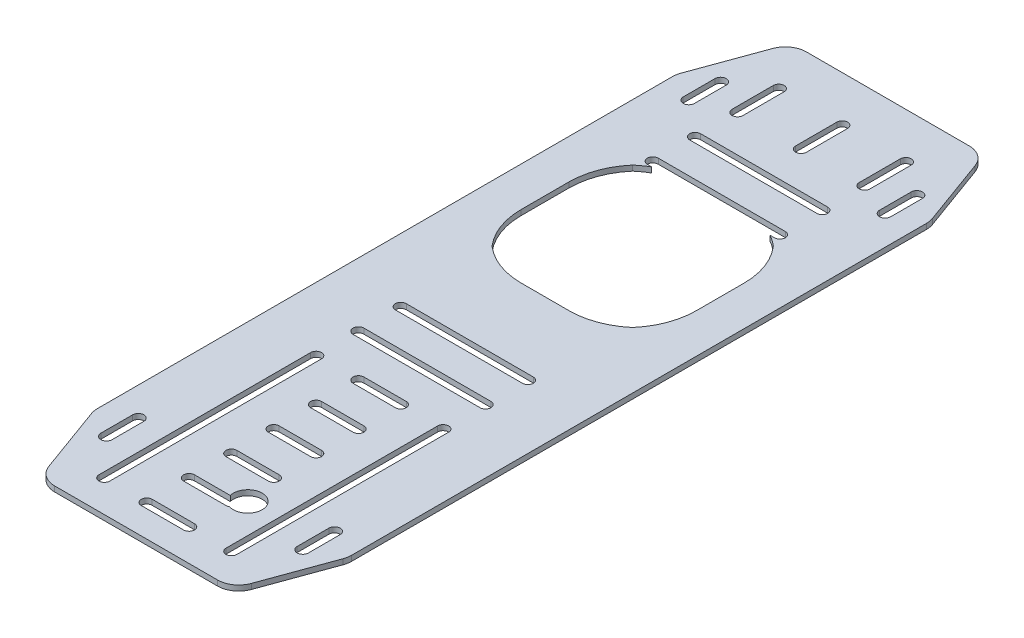
from build123d import *

# Parameters (mm, degrees)
SKETCH1_W               = 152.4
SKETCH1_H               = 660.4
BOSS_EXTRUDE1_DEPTH     = 3.18
CUT_EXTRUDE2_DEPTH      = 4.18
CUT_EXTRUDE3_DEPTH      = 4.18
CUT_EXTRUDE4_DEPTH      = 4.18
FILLET1_R               = 12.7
SKETCH6_R               = 8.636
CUT_EXTRUDE5_DEPTH      = 1
CUT_EXTRUDE5_DEPTH_BACK = 4.18
CUT_EXTRUDE6_REACH      = 5.18
SKETCH7_W               = 152.4
SKETCH7_H               = 209.55
CUT_EXTRUDE7_REACH      = 5.18
FILLET2_R               = 12.7
CUT_EXTRUDE8_REACH      = 5.18
SCALE1_SCALE            = 0.35


with BuildPart() as part:
    # Sketch1 → Boss-Extrude1 (new body)
    with BuildSketch(Plane(origin=(0, 0, 0), x_dir=(1, 0, 0), z_dir=(0, 1, 0))):
        Rectangle(SKETCH1_W, SKETCH1_H)
    extrude(amount=BOSS_EXTRUDE1_DEPTH)

    # Sketch3 → Cut-Extrude2 (cut, through all)
    with BuildSketch(Plane(origin=(0, 3.18, 0), x_dir=(1, 0, 0), z_dir=(0, 1, 0))):
        with BuildLine():
            Line((-38.1, 54.0639), (38.1, 54.0639))
            ThreePointArc((38.1, 54.0639), (41.3639, 50.8), (38.1, 47.5361))
            Line((38.1, 47.5361), (-38.1, 47.5361))
            ThreePointArc((-38.1, 47.5361), (-41.3639, 50.8), (-38.1, 54.0639))
        make_face()
        with BuildLine():
            Line((-41.3639, 25.4), (-41.3639, -101.6))
            ThreePointArc((-41.3639, -101.6), (-38.1, -104.8639), (-34.8361, -101.6))
            Line((-34.8361, -101.6), (-34.8361, 25.4))
            ThreePointArc((-34.8361, 25.4), (-38.1, 28.6639), (-41.3639, 25.4))
        make_face()
        with BuildLine():
            Line((41.3639, 25.4), (41.3639, -101.6))
            ThreePointArc((41.3639, -101.6), (38.1, -104.8639), (34.8361, -101.6))
            Line((34.8361, -101.6), (34.8361, 25.4))
            ThreePointArc((34.8361, 25.4), (38.1, 28.6639), (41.3639, 25.4))
        make_face()
        with BuildLine():
            Line((-38.1, -130.2639), (38.1, -130.2639))
            ThreePointArc((38.1, -130.2639), (41.3639, -127), (38.1, -123.7361))
            Line((38.1, -123.7361), (-38.1, -123.7361))
            ThreePointArc((-38.1, -123.7361), (-41.3639, -127), (-38.1, -130.2639))
        make_face()
        with BuildLine():
            Line((41.3639, -279.4), (41.3639, -152.4))
            ThreePointArc((41.3639, -152.4), (38.1, -149.1361), (34.8361, -152.4))
            Line((34.8361, -152.4), (34.8361, -279.4))
            ThreePointArc((34.8361, -279.4), (38.1, -282.6639), (41.3639, -279.4))
        make_face()
        with BuildLine():
            Line((-41.3639, -279.4), (-41.3639, -152.4))
            ThreePointArc((-41.3639, -152.4), (-38.1, -149.1361), (-34.8361, -152.4))
            Line((-34.8361, -152.4), (-34.8361, -279.4))
            ThreePointArc((-34.8361, -279.4), (-38.1, -282.6639), (-41.3639, -279.4))
        make_face()
        with BuildLine():
            Line((-38.1, -301.5361), (38.1, -301.5361))
            ThreePointArc((38.1, -301.5361), (41.3639, -304.8), (38.1, -308.0639))
            Line((38.1, -308.0639), (-38.1, -308.0639))
            ThreePointArc((-38.1, -308.0639), (-41.3639, -304.8), (-38.1, -301.5361))
        make_face()
        with BuildLine():
            Line((-12.7, -276.1361), (12.7, -276.1361))
            ThreePointArc((12.7, -276.1361), (15.9639, -279.4), (12.7, -282.6639))
            Line((12.7, -282.6639), (-12.7, -282.6639))
            ThreePointArc((-12.7, -282.6639), (-15.9639, -279.4), (-12.7, -276.1361))
        make_face()
        with BuildLine():
            Line((-12.7, -250.7361), (12.7, -250.7361))
            ThreePointArc((12.7, -250.7361), (15.9639, -254), (12.7, -257.2639))
            Line((12.7, -257.2639), (-12.7, -257.2639))
            ThreePointArc((-12.7, -257.2639), (-15.9639, -254), (-12.7, -250.7361))
        make_face()
        with BuildLine():
            Line((-12.7, -225.3361), (12.7, -225.3361))
            ThreePointArc((12.7, -225.3361), (15.9639, -228.6), (12.7, -231.8639))
            Line((12.7, -231.8639), (-12.7, -231.8639))
            ThreePointArc((-12.7, -231.8639), (-15.9639, -228.6), (-12.7, -225.3361))
        make_face()
        with BuildLine():
            Line((-12.7, -199.9361), (12.7, -199.9361))
            ThreePointArc((12.7, -199.9361), (15.9639, -203.2), (12.7, -206.4639))
            Line((12.7, -206.4639), (-12.7, -206.4639))
            ThreePointArc((-12.7, -206.4639), (-15.9639, -203.2), (-12.7, -199.9361))
        make_face()
        with BuildLine():
            Line((-12.7, -174.5361), (12.7, -174.5361))
            ThreePointArc((12.7, -174.5361), (15.9639, -177.8), (12.7, -181.0639))
            Line((12.7, -181.0639), (-12.7, -181.0639))
            ThreePointArc((-12.7, -181.0639), (-15.9639, -177.8), (-12.7, -174.5361))
        make_face()
        with BuildLine():
            Line((-12.7, -149.1361), (12.7, -149.1361))
            ThreePointArc((12.7, -149.1361), (15.9639, -152.4), (12.7, -155.6639))
            Line((12.7, -155.6639), (-12.7, -155.6639))
            ThreePointArc((-12.7, -155.6639), (-15.9639, -152.4), (-12.7, -149.1361))
        make_face()
        with BuildLine():
            Line((-12.7, 22.1361), (12.7, 22.1361))
            ThreePointArc((12.7, 22.1361), (15.9639, 25.4), (12.7, 28.6639))
            Line((12.7, 28.6639), (-12.7, 28.6639))
            ThreePointArc((-12.7, 28.6639), (-15.9639, 25.4), (-12.7, 22.1361))
        make_face()
        with BuildLine():
            Line((-12.7, -3.2639), (12.7, -3.2639))
            ThreePointArc((12.7, -3.2639), (15.9639, 0), (12.7, 3.2639))
            Line((12.7, 3.2639), (-12.7, 3.2639))
            ThreePointArc((-12.7, 3.2639), (-15.9639, 0), (-12.7, -3.2639))
        make_face()
        with BuildLine():
            Line((-12.7, -28.6639), (12.7, -28.6639))
            ThreePointArc((12.7, -28.6639), (15.9639, -25.4), (12.7, -22.1361))
            Line((12.7, -22.1361), (-12.7, -22.1361))
            ThreePointArc((-12.7, -22.1361), (-15.9639, -25.4), (-12.7, -28.6639))
        make_face()
        with BuildLine():
            Line((-12.7, -54.0639), (12.7, -54.0639))
            ThreePointArc((12.7, -54.0639), (15.9639, -50.8), (12.7, -47.5361))
            Line((12.7, -47.5361), (-12.7, -47.5361))
            ThreePointArc((-12.7, -47.5361), (-15.9639, -50.8), (-12.7, -54.0639))
        make_face()
        with BuildLine():
            Line((-12.7, -79.4639), (12.7, -79.4639))
            ThreePointArc((12.7, -79.4639), (15.9639, -76.2), (12.7, -72.9361))
            Line((12.7, -72.9361), (-12.7, -72.9361))
            ThreePointArc((-12.7, -72.9361), (-15.9639, -76.2), (-12.7, -79.4639))
        make_face()
        with BuildLine():
            Line((-12.7, -104.8639), (12.7, -104.8639))
            ThreePointArc((12.7, -104.8639), (15.9639, -101.6), (12.7, -98.3361))
            Line((12.7, -98.3361), (-12.7, -98.3361))
            ThreePointArc((-12.7, -98.3361), (-15.9639, -101.6), (-12.7, -104.8639))
        make_face()
        with BuildLine():
            Line((-38.1, 72.9361), (38.1, 72.9361))
            ThreePointArc((38.1, 72.9361), (41.3639, 76.2), (38.1, 79.4639))
            Line((38.1, 79.4639), (-38.1, 79.4639))
            ThreePointArc((-38.1, 79.4639), (-41.3639, 76.2), (-38.1, 72.9361))
        make_face()
        with BuildLine():
            Line((-38.1, 230.599488), (38.1, 230.599488))
            ThreePointArc((38.1, 230.599488), (41.3639, 227.335588), (38.1, 224.071688))
            Line((38.1, 224.071688), (-38.1, 224.071688))
            ThreePointArc((-38.1, 224.071688), (-41.3639, 227.335588), (-38.1, 230.599488))
        make_face()
        with BuildLine():
            Line((-38.1, 249.471688), (38.1, 249.471688))
            ThreePointArc((38.1, 249.471688), (41.3639, 252.735588), (38.1, 255.999488))
            Line((38.1, 255.999488), (-38.1, 255.999488))
            ThreePointArc((-38.1, 255.999488), (-41.3639, 252.735588), (-38.1, 249.471688))
        make_face()
        with BuildLine():
            Line((-34.8361, 302.83925906), (-34.8361, 278.135588))
            ThreePointArc((-34.8361, 278.135588), (-38.1, 274.871688), (-41.3639, 278.135588))
            Line((-41.3639, 278.135588), (-41.3639, 302.83925906))
            ThreePointArc((-41.3639, 302.83925906), (-38.1, 306.10315906), (-34.8361, 302.83925906))
        make_face()
        with BuildLine():
            Line((3.2639, 302.83925906), (3.2639, 278.135588))
            ThreePointArc((3.2639, 278.135588), (0, 274.871688), (-3.2639, 278.135588))
            Line((-3.2639, 278.135588), (-3.2639, 302.83925906))
            ThreePointArc((-3.2639, 302.83925906), (0, 306.10315906), (3.2639, 302.83925906))
        make_face()
        with BuildLine():
            Line((41.3639, 302.83925906), (41.3639, 278.135588))
            ThreePointArc((41.3639, 278.135588), (38.1, 274.871688), (34.8361, 278.135588))
            Line((34.8361, 278.135588), (34.8361, 302.83925906))
            ThreePointArc((34.8361, 302.83925906), (38.1, 306.10315906), (41.3639, 302.83925906))
        make_face()
    extrude(amount=-CUT_EXTRUDE2_DEPTH, mode=Mode.SUBTRACT)

    # Sketch4 → Cut-Extrude3 (cut, through all)
    with BuildSketch(Plane(origin=(0, 3.18, 0), x_dir=(1, 0, 0), z_dir=(0, 1, 0))):
        with BuildLine():
            Line((-14.361406616, 124.611310304), (14.361406616, 124.611310304))
            ThreePointArc((14.361406616, 124.611310304), (29.204496188, 127.284854581), (42.181875503, 134.969434801))
            ThreePointArc((42.181875503, 134.969434801), (49.866455724, 147.946814116), (52.54, 162.789903688))
            Line((52.54, 162.789903688), (52.54, 191.512716921))
            ThreePointArc((52.54, 191.512716921), (49.866455724, 206.355806493), (42.181875503, 219.333185808))
            ThreePointArc((42.181875503, 219.333185808), (29.204496188, 227.017766028), (14.361406616, 229.691310304))
            Line((14.361406616, 229.691310304), (-14.361406616, 229.691310304))
            ThreePointArc((-14.361406616, 229.691310304), (-29.204496188, 227.017766028), (-42.181875503, 219.333185808))
            ThreePointArc((-42.181875503, 219.333185808), (-49.866455724, 206.355806493), (-52.54, 191.512716921))
            Line((-52.54, 191.512716921), (-52.54, 162.789903688))
            ThreePointArc((-52.54, 162.789903688), (-49.866455724, 147.946814116), (-42.181875503, 134.969434801))
            ThreePointArc((-42.181875503, 134.969434801), (-29.204496188, 127.284854581), (-14.361406616, 124.611310304))
        make_face()
    extrude(amount=-CUT_EXTRUDE3_DEPTH, mode=Mode.SUBTRACT)

    # Sketch5 → Cut-Extrude4 (cut, through all)
    with BuildSketch(Plane.XZ):
        Polygon((76.2, 279.4), (57.710312099, 330.2), (76.2, 330.2), align=None)
        Polygon((-57.710312099, 330.2), (-76.2, 330.2), (-76.2, 279.4), align=None)
        Polygon((-76.2, -279.4), (-57.710312099, -330.2), (-76.2, -330.2), align=None)
        Polygon((57.710312099, -330.2), (76.2, -330.2), (76.2, -279.4), align=None)
    extrude(amount=-CUT_EXTRUDE4_DEPTH, mode=Mode.SUBTRACT)

    # Fillet1
    fillet1_edges = [part.edges().sort_by_distance(p)[0] for p in [
        (57.710312099, 1.59, -330.2),
        (76.2, 1.59, -279.4),
        (-76.2, 1.59, -279.4),
        (-57.710312099, 1.59, -330.2),
        (-57.710312099, 1.59, 330.2),
        (-76.2, 1.59, 279.4),
        (76.2, 1.59, 279.4),
        (57.710312099, 1.59, 330.2),
    ]]
    fillet(fillet1_edges, radius=FILLET1_R)

    # Sketch6 → Cut-Extrude5 (cut, two sides)
    with BuildSketch(Plane(origin=(0, 3.18, 0), x_dir=(1, 0, 0), z_dir=(0, 1, 0))) as cut_extrude5_sk:
        with Locations((17.106, -70.8034)):
            Circle(SKETCH6_R)
    extrude(amount=CUT_EXTRUDE5_DEPTH, mode=Mode.SUBTRACT)
    extrude(cut_extrude5_sk.sketch, amount=-CUT_EXTRUDE5_DEPTH_BACK, mode=Mode.SUBTRACT)

    # Sketch7 → Cut-Extrude6 (cut, up to next)
    with BuildSketch(Plane.XZ, mode=Mode.PRIVATE) as cut_extrude6_sk1:
        with Locations((0, 225.425)):
            Rectangle(SKETCH7_W, SKETCH7_H)
    cut_extrude6_tool1 = extrude(cut_extrude6_sk1.sketch, amount=-CUT_EXTRUDE6_REACH, mode=Mode.PRIVATE) & part.part
    add(cut_extrude6_tool1.solids().sort_by_distance((0, 0, 225.425))[0], mode=Mode.SUBTRACT)

    # Sketch8 → Cut-Extrude7 (cut, up to next)
    with BuildSketch(Plane.XZ, mode=Mode.PRIVATE) as cut_extrude7_sk1:
        Polygon((76.2, 69.85), (76.2, 120.65), (57.710312099, 120.65), align=None)
    cut_extrude7_tool1 = extrude(cut_extrude7_sk1.sketch, amount=-CUT_EXTRUDE7_REACH, mode=Mode.PRIVATE) & part.part
    add(cut_extrude7_tool1.solids().sort_by_distance((70.036771, 0, 103.716667))[0], mode=Mode.SUBTRACT)
    # Sketch8 → Cut-Extrude7 (cut, up to next)
    with BuildSketch(Plane.XZ, mode=Mode.PRIVATE) as cut_extrude7_sk2:
        Polygon((-76.2, 120.65), (-57.710312099, 120.65), (-76.2, 69.85), align=None)
    cut_extrude7_tool2 = extrude(cut_extrude7_sk2.sketch, amount=-CUT_EXTRUDE7_REACH, mode=Mode.PRIVATE) & part.part
    add(cut_extrude7_tool2.solids().sort_by_distance((-70.036771, 0, 103.716667))[0], mode=Mode.SUBTRACT)

    # Fillet2
    fillet2_edges = [part.edges().sort_by_distance(p)[0] for p in [
        (76.2, 1.59, 69.85),
        (57.710312099, 1.59, 120.65),
        (-76.2, 1.59, 69.85),
        (-57.710312099, 1.59, 120.65),
    ]]
    fillet(fillet2_edges, radius=FILLET2_R)

    # Sketch9 → Cut-Extrude8 (cut, up to next)
    with BuildSketch(Plane.XZ, mode=Mode.PRIVATE) as cut_extrude8_sk1:
        with BuildLine():
            Line((62.052200001, -269.875), (62.052200001, -288.925))
            ThreePointArc((62.052200001, -288.925), (58.674000001, -292.3032), (55.295800001, -288.925))
            Line((55.295800001, -288.925), (55.295800001, -269.875))
            ThreePointArc((55.295800001, -269.875), (58.674000001, -266.4968), (62.052200001, -269.875))
        make_face()
    cut_extrude8_tool1 = extrude(cut_extrude8_sk1.sketch, amount=-CUT_EXTRUDE8_REACH, mode=Mode.PRIVATE) & part.part
    add(cut_extrude8_tool1.solids().sort_by_distance((58.674, 0, -279.4))[0], mode=Mode.SUBTRACT)
    # Sketch9 → Cut-Extrude8 (cut, up to next)
    with BuildSketch(Plane.XZ, mode=Mode.PRIVATE) as cut_extrude8_sk2:
        with BuildLine():
            Line((-55.657585683, -269.875), (-55.657585683, -288.925))
            ThreePointArc((-55.657585683, -288.925), (-59.035785683, -292.3032), (-62.413985683, -288.925))
            Line((-62.413985683, -288.925), (-62.413985683, -269.875))
            ThreePointArc((-62.413985683, -269.875), (-59.035785683, -266.4968), (-55.657585683, -269.875))
        make_face()
    cut_extrude8_tool2 = extrude(cut_extrude8_sk2.sketch, amount=-CUT_EXTRUDE8_REACH, mode=Mode.PRIVATE) & part.part
    add(cut_extrude8_tool2.solids().sort_by_distance((-59.035786, 0, -279.4))[0], mode=Mode.SUBTRACT)
    # Sketch9 → Cut-Extrude8 (cut, up to next)
    with BuildSketch(Plane.XZ, mode=Mode.PRIVATE) as cut_extrude8_sk3:
        with BuildLine():
            Line((-55.657585683, 60.325), (-55.657585683, 79.375))
            ThreePointArc((-55.657585683, 79.375), (-59.035785683, 82.7532), (-62.413985683, 79.375))
            Line((-62.413985683, 79.375), (-62.413985683, 60.325))
            ThreePointArc((-62.413985683, 60.325), (-59.035785683, 56.9468), (-55.657585683, 60.325))
        make_face()
    cut_extrude8_tool3 = extrude(cut_extrude8_sk3.sketch, amount=-CUT_EXTRUDE8_REACH, mode=Mode.PRIVATE) & part.part
    add(cut_extrude8_tool3.solids().sort_by_distance((-59.035786, 0, 69.85))[0], mode=Mode.SUBTRACT)
    # Sketch9 → Cut-Extrude8 (cut, up to next)
    with BuildSketch(Plane.XZ, mode=Mode.PRIVATE) as cut_extrude8_sk4:
        with BuildLine():
            Line((62.052200001, 60.325), (62.052200001, 79.375))
            ThreePointArc((62.052200001, 79.375), (58.674000001, 82.7532), (55.295800001, 79.375))
            Line((55.295800001, 79.375), (55.295800001, 60.325))
            ThreePointArc((55.295800001, 60.325), (58.674000001, 56.9468), (62.052200001, 60.325))
        make_face()
    cut_extrude8_tool4 = extrude(cut_extrude8_sk4.sketch, amount=-CUT_EXTRUDE8_REACH, mode=Mode.PRIVATE) & part.part
    add(cut_extrude8_tool4.solids().sort_by_distance((58.674, 0, 69.85))[0], mode=Mode.SUBTRACT)


with BuildPart() as part_1:
    # Scale1: scaled about (-0.0693639, 1.59, -96.26928837)
    add(part.part.scale(SCALE1_SCALE).moved(Location((-0.045086535, 1.0335, -62.575037441))))


solid = part_1.part
